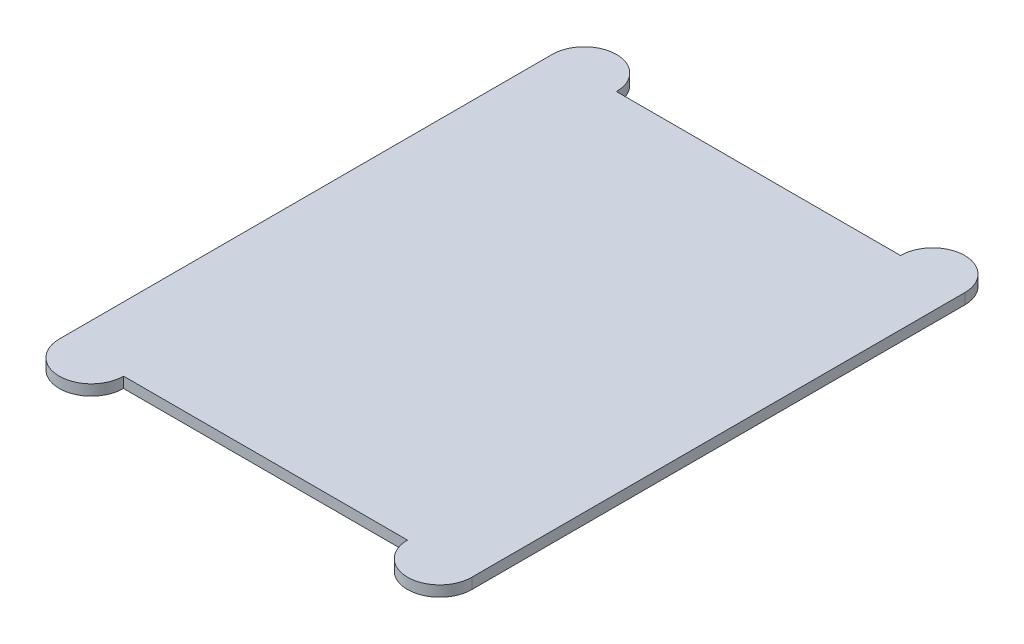
from build123d import *

# Parameters (mm, degrees)
BOSS_EXTRUDE1_DEPTH        = 10
SKETCH2_W                  = 200
SKETCH2_H                  = 300
BOSS_EXTRUDE2_DEPTH        = 5
SKETCH3_W                  = 200
SKETCH3_H                  = 300
SKETCH3_R                  = 10
BOSS_EXTRUDE3_DEPTH        = 10
SKETCH4_R                  = 2.5
BOSS_EXTRUDE4_DEPTH        = 25
SKETCH5_R                  = 10
BOSS_EXTRUDE5_DEPTH        = 2
SKETCH6_W                  = 105
SKETCH6_H                  = 15
BOSS_EXTRUDE6_DEPTH        = 50
SKETCH7_R                  = 10
CUT_EXTRUDE1_DEPTH         = 391.123452904
SKETCH8_R                  = 25
BOSS_EXTRUDE7_DEPTH        = 5
SKETCH9_R                  = 10
BOSS_EXTRUDE8_DEPTH        = 20
BOSS_EXTRUDE8_DEPTH_BACK   = 15
BOSS_EXTRUDE8_2_DEPTH      = 20
BOSS_EXTRUDE8_2_DEPTH_BACK = 15
SKETCH10_R                 = 10
BOSS_EXTRUDE10_DEPTH       = 20
BOSS_EXTRUDE10_DEPTH_BACK  = 15
SKETCH11_R                 = 12.5
CUT_EXTRUDE2_DEPTH         = 1


with BuildPart() as part:
    # Sketch1 → Boss-Extrude1 (new body)
    with BuildSketch(Plane(origin=(0, 0, 0), x_dir=(1, 0, 0), z_dir=(0, 1, 0))):
        with BuildLine():
            Line((-132.5, 230), (132.5, 230))
            ThreePointArc((132.5, 230), (162.5, 260), (192.5, 230))
            Line((192.5, 230), (192.5, -230))
            ThreePointArc((192.5, -230), (162.5, -260), (132.5, -230))
            Line((132.5, -230), (-132.5, -230))
            ThreePointArc((-132.5, -230), (-162.5, -260), (-192.5, -230))
            Line((-192.5, -230), (-192.5, 230))
            ThreePointArc((-192.5, 230), (-162.5, 260), (-132.5, 230))
        make_face()
    extrude(amount=BOSS_EXTRUDE1_DEPTH)

    # Sketch2 → Boss-Extrude2 (add)
    with BuildSketch(Plane.XZ):
        Rectangle(SKETCH2_W, SKETCH2_H)
    extrude(amount=BOSS_EXTRUDE2_DEPTH)

    # Sketch3 → Boss-Extrude3 (add)
    with BuildSketch(Plane.XZ.offset(5)):
        Rectangle(SKETCH3_W, SKETCH3_H)
        with Locations((72.114197452, 0)):
            Circle(SKETCH3_R, mode=Mode.SUBTRACT)
        with Locations((-73.278550608, 0)):
            Circle(SKETCH3_R, mode=Mode.SUBTRACT)
        with Locations((-73.278550608, 75)):
            Circle(SKETCH3_R, mode=Mode.SUBTRACT)
        with Locations((72.114197452, 75)):
            Circle(SKETCH3_R, mode=Mode.SUBTRACT)
        with Locations((72.114197452, -75)):
            Circle(SKETCH3_R, mode=Mode.SUBTRACT)
        with Locations((-73.278550608, -75)):
            Circle(SKETCH3_R, mode=Mode.SUBTRACT)
    extrude(amount=BOSS_EXTRUDE3_DEPTH)

    # Sketch4 → Boss-Extrude4 (add)
    with BuildSketch(Plane.XZ.offset(5)):
        with Locations((-73.278550608, 75)):
            Circle(SKETCH4_R)
        with Locations((72.114197452, 75)):
            Circle(SKETCH4_R)
        with Locations((-73.278550608, 0)):
            Circle(SKETCH4_R)
        with Locations((-73.278550608, -75)):
            Circle(SKETCH4_R)
        with Locations((72.114197452, 0)):
            Circle(SKETCH4_R)
        with Locations((72.114197452, -75)):
            Circle(SKETCH4_R)
    extrude(amount=BOSS_EXTRUDE4_DEPTH)

    # Sketch5 → Boss-Extrude5 (add)
    with BuildSketch(Plane.XZ.offset(30)):
        with Locations((-73.278550608, 0)):
            Circle(SKETCH5_R)
        with Locations((-73.278550608, 75)):
            Circle(SKETCH5_R)
        with Locations((72.114197452, 75)):
            Circle(SKETCH5_R)
        with Locations((72.114197452, 0)):
            Circle(SKETCH5_R)
        with Locations((72.114197452, -75)):
            Circle(SKETCH5_R)
        with Locations((-73.278550608, -75)):
            Circle(SKETCH5_R)
    extrude(amount=BOSS_EXTRUDE5_DEPTH)

    # Sketch6 → Boss-Extrude6 (add)
    with BuildSketch(Plane.XZ.offset(15)):
        with Locations((0, 122.623452904)):
            Rectangle(SKETCH6_W, SKETCH6_H)
        with Locations((0, -122.623452904)):
            Rectangle(SKETCH6_W, SKETCH6_H)
    extrude(amount=BOSS_EXTRUDE6_DEPTH)

    # Sketch7 → Cut-Extrude1 (cut, through all)
    with BuildSketch(Plane.XY.offset(130.123452904)):
        with Locations((37.5, -40)):
            Circle(SKETCH7_R)
        with Locations((-37.5, -40)):
            Circle(SKETCH7_R)
    extrude(amount=-CUT_EXTRUDE1_DEPTH, mode=Mode.SUBTRACT)

    # Sketch8 → Boss-Extrude7 (add)
    with BuildSketch(Plane.XZ):
        with Locations((157.5, 0)):
            Circle(SKETCH8_R)
        with Locations((-157.5, 0)):
            Circle(SKETCH8_R)
    extrude(amount=BOSS_EXTRUDE7_DEPTH)

    # Sketch10 → Boss-Extrude10 (add, two sides)
    with BuildSketch(Plane(origin=(0, 0, -130.123452904), x_dir=(-1, 0, 0), z_dir=(0, 0, -1))) as boss_extrude10_sk:
        with Locations((37.5, -40)):
            Circle(SKETCH10_R)
        with Locations((-37.5, -40)):
            Circle(SKETCH10_R)
    extrude(amount=BOSS_EXTRUDE10_DEPTH)
    extrude(boss_extrude10_sk.sketch, amount=-BOSS_EXTRUDE10_DEPTH_BACK)

    # Sketch11 → Cut-Extrude2 (cut)
    with BuildSketch(Plane.XZ.offset(15)):
        Circle(SKETCH11_R)
    extrude(amount=-CUT_EXTRUDE2_DEPTH, mode=Mode.SUBTRACT)


with BuildPart() as body_2:
    # Sketch9 → Boss-Extrude8 (new body, two sides)
    with BuildSketch(Plane.XY.offset(130.123452904)) as boss_extrude8_sk:
        with Locations((37.5, -40)):
            Circle(SKETCH9_R)
    extrude(amount=BOSS_EXTRUDE8_DEPTH)
    extrude(boss_extrude8_sk.sketch, amount=-BOSS_EXTRUDE8_DEPTH_BACK)


with BuildPart() as body_3:
    # Sketch9 → Boss-Extrude8 2 (new body, two sides)
    with BuildSketch(Plane.XY.offset(130.123452904)) as boss_extrude8_2_sk:
        with Locations((-37.5, -40)):
            Circle(SKETCH9_R)
    extrude(amount=BOSS_EXTRUDE8_2_DEPTH)
    extrude(boss_extrude8_2_sk.sketch, amount=-BOSS_EXTRUDE8_2_DEPTH_BACK)


solid = Compound([part.part, body_2.part, body_3.part])
